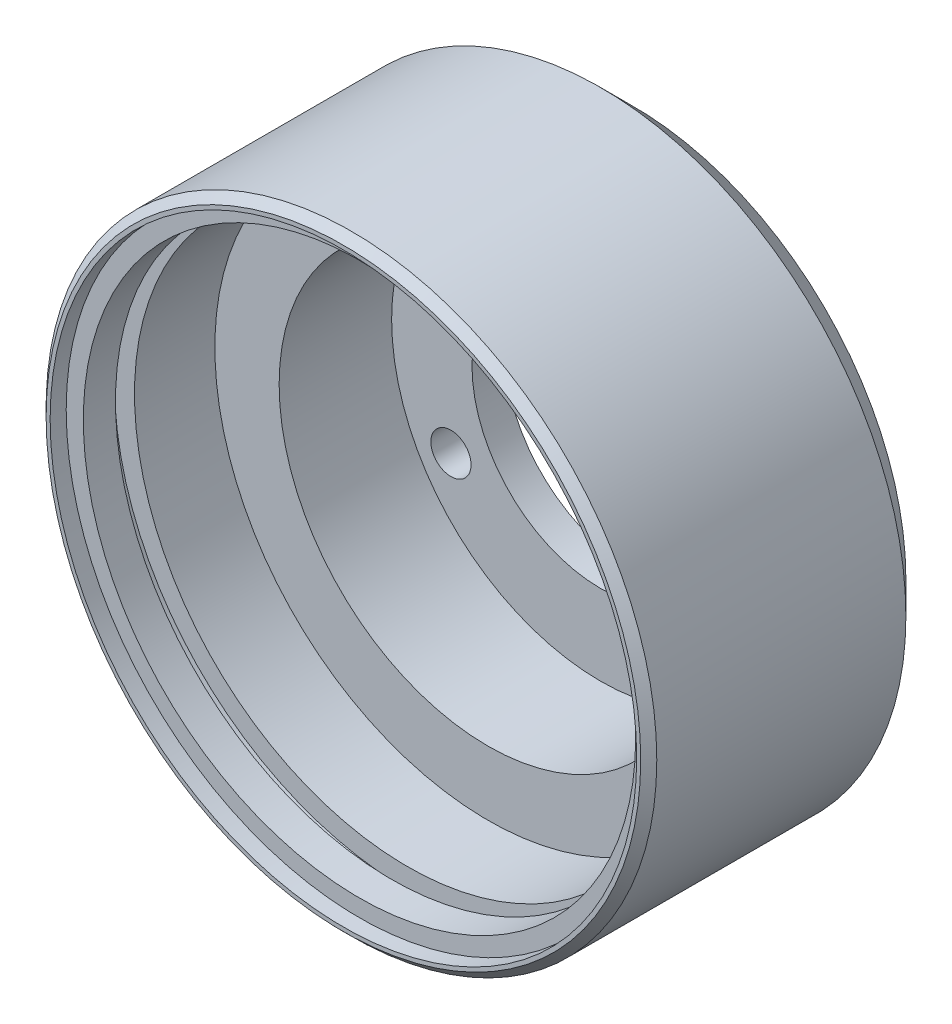
from build123d import *

# Parameters (mm, degrees)
ESQUISSE1_R                  = 19
BASE_EXTRUSION_DEPTH         = 18
ESQUISSE2_R                  = 13
ENL_V_MAT_EXTRU_1_DEPTH      = 14
ESQUISSE3_R                  = 8
ENL_V_MAT_EXTRU_2_DEPTH      = 19
ESQUISSE4_R                  = 1.25
ENL_V_MAT_EXTRU_3_DEPTH      = 19
R_P_TITION_CIRCULAIRE1_COUNT = 3
ESQUISSE5_R                  = 13
ENL_V_MAT_EXTRU_4_DEPTH      = 2
ESQUISSE6_R                  = 18.25
ENL_V_MAT_EXTRU_5_DEPTH      = 1
ESQUISSE7_R                  = 17
ENL_V_MAT_EXTRU_6_DEPTH      = 10
ESQUISSE8_R                  = 17.185
ENL_V_MAT_EXTRU_7_DEPTH      = 4
ESQUISSE9_R                  = 18.25
ENL_V_MAT_EXTRU_8_DEPTH      = 1
CHANFREIN1_SIZE              = 2
CHANFREIN2_SIZE              = 0.5


with BuildPart() as part:
    # Esquisse1 → Base-Extrusion (new body)
    with BuildSketch(Plane.XY):
        Circle(ESQUISSE1_R)
    extrude(amount=BASE_EXTRUSION_DEPTH)

    # Esquisse2 → Enlèv. mat.-Extru.1 (cut)
    with BuildSketch(Plane.XY.offset(18)):
        Circle(ESQUISSE2_R)
    extrude(amount=-ENL_V_MAT_EXTRU_1_DEPTH, mode=Mode.SUBTRACT)

    # Esquisse3 → Enlèv. mat.-Extru.2 (cut, through all)
    with BuildSketch(Plane(origin=(0, 0, 0), x_dir=(-1, 0, 0), z_dir=(0, 0, -1))):
        Circle(ESQUISSE3_R)
    extrude(amount=-ENL_V_MAT_EXTRU_2_DEPTH, mode=Mode.SUBTRACT)

    # Esquisse4 → Enlèv. mat.-Extru.3 (cut, through all)
    with BuildSketch(Plane(origin=(0, 0, 0), x_dir=(-1, 0, 0), z_dir=(0, 0, -1))):
        with Locations((0, 10.75)):
            Circle(ESQUISSE4_R)
    enl_v_mat_extru_3 = extrude(amount=-ENL_V_MAT_EXTRU_3_DEPTH, mode=Mode.SUBTRACT)

    # Répétition circulaire1: Enlèv. mat.-Extru.3 ×3 about axis
    r_p_tition_circulaire1_axis = Axis((0, 0, 0), (0, 0, -1))
    for i in range(1, R_P_TITION_CIRCULAIRE1_COUNT):
        add(enl_v_mat_extru_3.rotate(r_p_tition_circulaire1_axis, i * 360 / R_P_TITION_CIRCULAIRE1_COUNT), mode=Mode.SUBTRACT)

    # Esquisse5 → Enlèv. mat.-Extru.4 (cut)
    with BuildSketch(Plane.XY.offset(4)):
        Circle(ESQUISSE5_R)
    extrude(amount=-ENL_V_MAT_EXTRU_4_DEPTH, mode=Mode.SUBTRACT)

    # Esquisse6 → Enlèv. mat.-Extru.5 (cut)
    with BuildSketch(Plane.XY.offset(18)):
        Circle(ESQUISSE6_R)
    extrude(amount=-ENL_V_MAT_EXTRU_5_DEPTH, mode=Mode.SUBTRACT)

    # Esquisse7 → Enlèv. mat.-Extru.6 (cut, through all)
    with BuildSketch(Plane.XY.offset(9)):
        Circle(ESQUISSE7_R)
    extrude(amount=ENL_V_MAT_EXTRU_6_DEPTH, mode=Mode.SUBTRACT)

    # Esquisse8 → Enlèv. mat.-Extru.7 (cut)
    with BuildSketch(Plane.XY.offset(18)):
        Circle(ESQUISSE8_R)
    extrude(amount=-ENL_V_MAT_EXTRU_7_DEPTH, mode=Mode.SUBTRACT)

    # Esquisse9 → Enlèv. mat.-Extru.8 (cut)
    with BuildSketch(Plane.XY.offset(14)):
        Circle(ESQUISSE9_R)
    extrude(amount=ENL_V_MAT_EXTRU_8_DEPTH, mode=Mode.SUBTRACT)

    # Chanfrein1
    chanfrein1_edges = [part.edges().sort_by_distance(p)[0] for p in [
        (-19, 0, 0),
    ]]
    chamfer(chanfrein1_edges, length=CHANFREIN1_SIZE)

    # Chanfrein2
    chanfrein2_edges = [part.edges().sort_by_distance(p)[0] for p in [
        (-19, 0, 18),
    ]]
    chamfer(chanfrein2_edges, length=CHANFREIN2_SIZE)


solid = part.part
